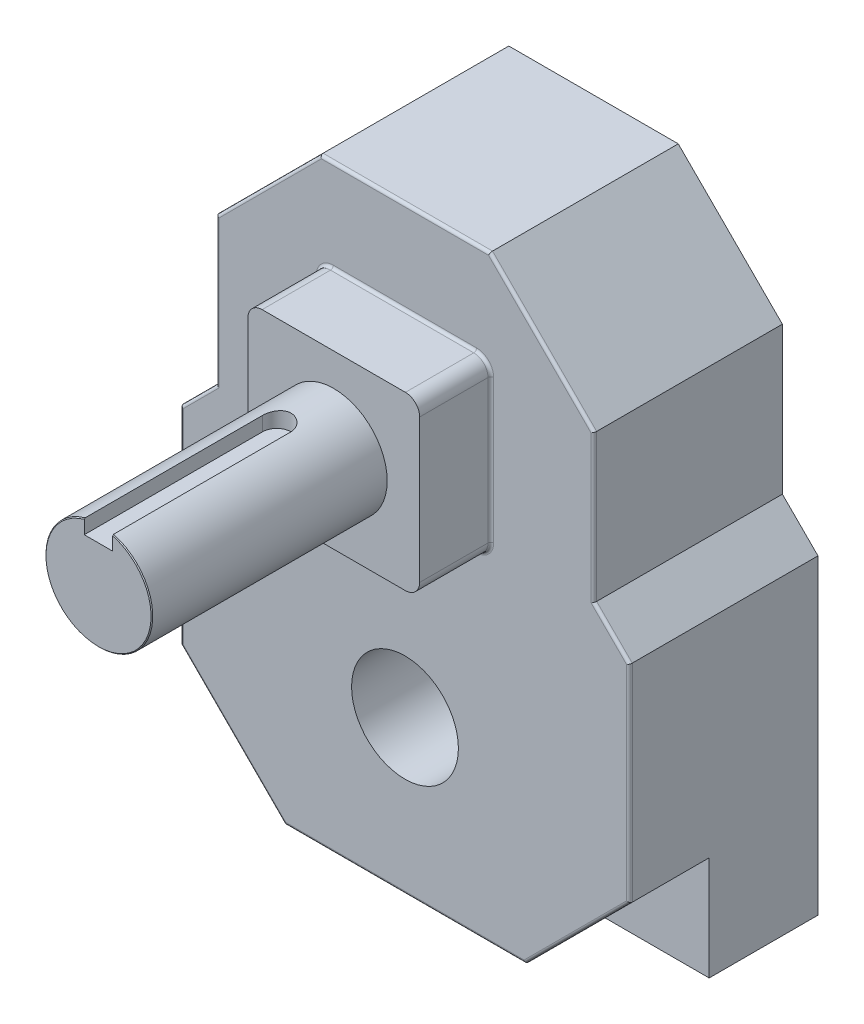
from build123d import *

# Parameters (mm, degrees)
BOSS_EXTRUDE1_DEPTH = 84.074
SKETCH3_W           = 76.581
SKETCH3_H           = 76.581
BOSS_EXTRUDE2_DEPTH = 31.75
SKETCH_D_R          = 23.8125
BOSS_EXTRUDE3_DEPTH = 104.902
CUT_EXTRUDE1_DEPTH  = 35.56
FILLET1_R           = 6.35
FILLET2_R           = 1.27
KEYWAY_START        = 16.5989
KEYWAY_DEPTH        = 63.6491
CHAMFER1_SIZE       = 0.381
SKETCH7_R           = 23.8125
CUT_EXTRUDE3_DEPTH  = 221.726


with BuildPart() as part:
    # L,M → Boss-Extrude1 (new body)
    with BuildSketch(Plane.XY):
        Polygon((-100.076, 68.326), (100.076, 68.326), (100.076, 207.077403609), (84.201, 222.952403609), (84.201, 288.603596391), (37.778596391, 335.026), (-37.778596391, 335.026), (-84.201, 288.603596391), (-84.201, 222.952403609), (-100.076, 207.077403609), align=None)
    extrude(amount=BOSS_EXTRUDE1_DEPTH)

    # Sketch3 → Boss-Extrude2 (add)
    with BuildSketch(Plane.XY.offset(84.074)):
        with Locations((0, 255.778)):
            Rectangle(SKETCH3_W, SKETCH3_H)
    extrude(amount=BOSS_EXTRUDE2_DEPTH)

    # D → Boss-Extrude3 (add)
    with BuildSketch(Plane.XY.offset(115.824)):
        with Locations((0, 255.778)):
            Circle(SKETCH_D_R)
    extrude(amount=BOSS_EXTRUDE3_DEPTH)

    # Sketch5 → Cut-Extrude1 (cut)
    with BuildSketch(Plane.XY.offset(84.074)):
        Polygon((100.076, 114.748403609), (53.653596391, 68.326), (100.076, 68.326), align=None)
        Polygon((-100.076, 68.326), (-100.076, 114.748403609), (-53.653596391, 68.326), align=None)
    extrude(amount=-CUT_EXTRUDE1_DEPTH, mode=Mode.SUBTRACT)

    # Fillet1
    fillet1_edges = [part.edges().sort_by_distance(p)[0] for p in [
        (-38.2905, 294.0685, 99.949),
        (-38.2905, 217.4875, 99.949),
        (38.2905, 217.4875, 99.949),
        (38.2905, 294.0685, 99.949),
    ]]
    fillet(fillet1_edges, radius=FILLET1_R)

    # Fillet2
    fillet2_edges = [part.edges().sort_by_distance(p)[0] for p in [
        (100.076, 160.912903609, 84.074),
        (76.864798195, 91.537201805, 84.074),
        (92.1385, 215.014903609, 84.074),
        (84.201, 255.778, 84.074),
        (60.989798195, 311.814798195, 84.074),
        (0, 335.026, 84.074),
        (0, 68.326, 84.074),
        (-60.989798195, 311.814798195, 84.074),
        (-84.201, 255.778, 84.074),
        (-92.1385, 215.014903609, 84.074),
        (-100.076, 160.912903609, 84.074),
        (-76.864798195, 91.537201805, 84.074),
        (0, 217.4875, 84.074),
        (-38.2905, 255.778, 84.074),
        (38.2905, 255.778, 84.074),
        (0, 294.0685, 84.074),
        (-36.430628061, 219.347371939, 84.074),
        (36.430628061, 219.347371939, 84.074),
        (-36.430628061, 292.208628061, 84.074),
        (36.430628061, 292.208628061, 84.074),
    ]]
    fillet(fillet2_edges, radius=FILLET2_R)

    # Sketch6 → Keyway (cut, through all)
    with BuildSketch(Plane(origin=(0, 255.778, 0), x_dir=(-1, 0, 0), z_dir=(0, 1, 0)).offset(KEYWAY_START)):
        with BuildLine():
            Line((6.35, 220.726), (6.35, 141.224))
            ThreePointArc((6.35, 141.224), (0, 134.874), (-6.35, 141.224))
            Line((-6.35, 141.224), (-6.35, 220.726))
            ThreePointArc((-6.35, 220.726), (0, 227.076), (6.35, 220.726))
        make_face()
    extrude(amount=KEYWAY_DEPTH, mode=Mode.SUBTRACT)

    # Chamfer1
    chamfer1_edges = [part.edges().sort_by_distance(p)[0] for p in [
        (-14.419184811, 236.827478487, 220.726),
    ]]
    chamfer(chamfer1_edges, length=CHAMFER1_SIZE)

    # Sketch7 → Cut-Extrude3 (cut, through all)
    with BuildSketch(Plane(origin=(0, 0, 0), x_dir=(-1, 0, 0), z_dir=(0, 0, -1))):
        with Locations((0, 136.652)):
            Circle(SKETCH7_R)
    extrude(amount=-CUT_EXTRUDE3_DEPTH, mode=Mode.SUBTRACT)


solid = part.part
